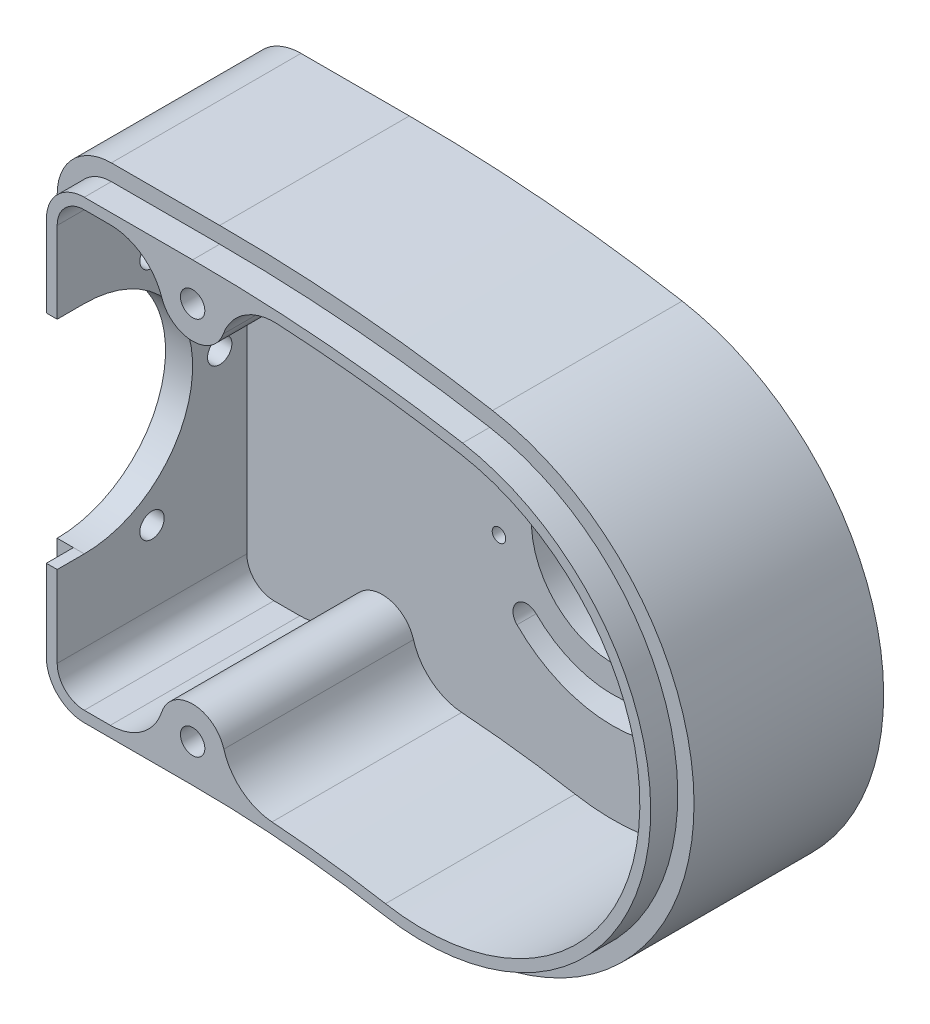
from build123d import *

# Parameters (mm, degrees)
EXTRUDE_1_DEPTH              = 35
CUT_EXTRUDE_1_DEPTH          = 30
SKETCH_3_R                   = 20
SKETCH_3_R_2                 = 2.25
CUT_EXTRUDE_2_DEPTH          = 10
SKETCH_4_R                   = 15
CUT_EXTRUDE_3_DEPTH          = 1
CUT_EXTRUDE_3_DEPTH_BACK     = 36
EXTRUDE_2_DEPTH              = 5
CUT_EXTRUDE_6_REACH          = 42
SKETCH_12_R                  = 6
EXTRUDE_3_DEPTH              = 35
FILLET_1_R                   = 10
HOLE_WIZARD_M2_1_D           = 1.6
HOLE_WIZARD_M2_1_DEPTH       = 5
HOLE_WIZARD_M3_1_D           = 2.5
HOLE_WIZARD_M3_1_DEPTH       = 5
HOLE_WIZARD_M4_6_D           = 4.5
HOLE_WIZARD_M4_6_DEPTH       = 40
HOLE_WIZARD_M4_6_CBORE_D     = 9
HOLE_WIZARD_M4_6_CBORE_DEPTH = 33.1
HOLE_WIZARD_M4_6_TIP         = 1.351936393


with BuildPart() as part:
    # 스케치1 → 보스-돌출1 (new body)
    with BuildSketch(Plane.XY):
        with BuildLine():
            Line((10, 45.518523903), (0, 45.518523903))
            Line((0, 45.518523903), (-10, 45.518523903))
            ThreePointArc((-10, 45.518523903), (-17.071067812, 42.589591715), (-20, 35.518523903))
            Line((-20, 35.518523903), (-20, -34.481476097))
            ThreePointArc((-20, -34.481476097), (-17.071067812, -41.552543909), (-10, -44.481476097))
            Line((-10, -44.481476097), (0, -44.481476097))
            Line((0, -44.481476097), (10, -44.481476097))
            ThreePointArc((10, -44.481476097), (27.43114855, -45.242536479), (44.729635533, -47.519925495))
            ThreePointArc((44.729635533, -47.519925495), (96.860152414, -11.017744604), (60.357971523, 41.112772276))
            ThreePointArc((60.357971523, 41.112772276), (35.275165397, 44.414986349), (10, 45.518523903))
        make_face()
    extrude(amount=EXTRUDE_1_DEPTH)

    # 스케치2 → 컷-돌출1 (cut)
    with BuildSketch(Plane.XY.offset(35)):
        with BuildLine():
            Line((10, 40.518523903), (-10, 40.518523903))
            ThreePointArc((-10, 40.518523903), (-13.535533906, 39.054057809), (-15, 35.518523903))
            Line((-15, 35.518523903), (-15, -34.481476097))
            ThreePointArc((-15, -34.481476097), (-13.535533906, -38.017010003), (-10, -39.481476097))
            Line((-10, -39.481476097), (10, -39.481476097))
            ThreePointArc((10, -39.481476097), (27.866927263, -40.261562989), (45.597876422, -42.59588673))
            ThreePointArc((45.597876422, -42.59588673), (91.936113649, -10.149503716), (59.489730635, 36.188733511))
            ThreePointArc((59.489730635, 36.188733511), (34.839386683, 39.434012859), (10, 40.518523903))
        make_face()
    extrude(amount=-CUT_EXTRUDE_1_DEPTH, mode=Mode.SUBTRACT)

    # 스케치3 → 컷-돌출2 (cut)
    with BuildSketch(Plane.ZY.offset(20)):
        with Locations((35, 0.518523903)):
            Circle(SKETCH_3_R)
        with Locations((22.5, 22.169158997)):
            Circle(SKETCH_3_R_2)
        with Locations((10, 0.518523903)):
            Circle(SKETCH_3_R_2)
        with Locations((22.5, -21.132111192)):
            Circle(SKETCH_3_R_2)
    extrude(amount=-CUT_EXTRUDE_2_DEPTH, mode=Mode.SUBTRACT)

    # 스케치4 → 컷-돌출3 (cut, two sides)
    with BuildSketch(Plane(origin=(0, 0, 0), x_dir=(-1, 0, 0), z_dir=(0, 0, -1))) as cut_extrude_3_sk:
        with Locations((-52.543803528, -3.203576609)):
            Circle(SKETCH_4_R)
    extrude(amount=CUT_EXTRUDE_3_DEPTH, mode=Mode.SUBTRACT)
    extrude(cut_extrude_3_sk.sketch, amount=-CUT_EXTRUDE_3_DEPTH_BACK, mode=Mode.SUBTRACT)

    # 스케치8 → 보스-돌출2 (add)
    with BuildSketch(Plane.XY.offset(35)):
        with BuildLine():
            Line((-15, -19.481476097), (-15, -34.481476097))
            ThreePointArc((-15, -34.481476097), (-13.535533906, -38.017010003), (-10, -39.481476097))
            Line((-10, -39.481476097), (10, -39.481476097))
            ThreePointArc((10, -39.481476097), (27.866927263, -40.261562989), (45.597876422, -42.59588673))
            ThreePointArc((45.597876422, -42.59588673), (91.936113649, -10.149503716), (59.489730635, 36.188733511))
            ThreePointArc((59.489730635, 36.188733511), (34.839386683, 39.434012859), (10, 40.518523903))
            Line((10, 40.518523903), (-10, 40.518523903))
            ThreePointArc((-10, 40.518523903), (-13.535533906, 39.054057809), (-15, 35.518523903))
            Line((-15, 35.518523903), (-15, 20.518523903))
            Line((-15, 20.518523903), (-17, 20.518523903))
            Line((-17, 20.518523903), (-17, 35.518523903))
            ThreePointArc((-17, 35.518523903), (-14.949747468, 40.468271371), (-10, 42.518523903))
            Line((-10, 42.518523903), (10, 42.518523903))
            ThreePointArc((10, 42.518523903), (35.013698169, 41.426402255), (59.83702699, 38.158349017))
            ThreePointArc((59.83702699, 38.158349017), (93.905729155, -10.496800071), (45.250580066, -44.565502236))
            ThreePointArc((45.250580066, -44.565502236), (27.692615778, -42.253952385), (10, -41.481476097))
            Line((10, -41.481476097), (-10, -41.481476097))
            ThreePointArc((-10, -41.481476097), (-14.949747468, -39.431223566), (-17, -34.481476097))
            Line((-17, -34.481476097), (-17, -19.481476097))
            Line((-17, -19.481476097), (-15, -19.481476097))
        make_face()
    extrude(amount=EXTRUDE_2_DEPTH)

    # 스케치9 → 컷-돌출6 (cut, up to next)
    with BuildSketch(Plane(origin=(0, 0, 0), x_dir=(-1, 0, 0), z_dir=(0, 0, -1)), mode=Mode.PRIVATE) as cut_extrude_6_sk1:
        with BuildLine():
            ThreePointArc((-38.401667905, 10.938559014), (-34.866133999, 10.938559014), (-34.866133999, 14.47409292))
            ThreePointArc((-34.866133999, 14.47409292), (-77.543803528, -3.203576609), (-34.866133999, -20.881246139))
            ThreePointArc((-34.866133999, -20.881246139), (-34.866133999, -17.345712233), (-38.401667905, -17.345712233))
            ThreePointArc((-38.401667905, -17.345712233), (-72.543803528, -3.203576609), (-38.401667905, 10.938559014))
        make_face()
    cut_extrude_6_tool1 = extrude(cut_extrude_6_sk1.sketch, amount=-CUT_EXTRUDE_6_REACH, mode=Mode.PRIVATE) & part.part
    add(cut_extrude_6_tool1.solids().sort_by_distance((35.334344, -17.813923, 0))[0], mode=Mode.SUBTRACT)

    # 스케치12 → 보스-돌출3 (add)
    with BuildSketch(Plane.XY.offset(5)):
        with Locations((10, 35.518523903)):
            Circle(SKETCH_12_R)
        with Locations((10, -34.481476097)):
            Circle(SKETCH_12_R)
    extrude(amount=EXTRUDE_3_DEPTH)

    # 필렛1
    fillet_1_edges = [part.edges().sort_by_distance(p)[0] for p in [
        (13.346048824, 40.498881046, 22.5),
        (6.68337521, 40.518523903, 22.5),
        (13.276798635, -39.507666574, 22.5),
        (6.68337521, -39.481476097, 22.5),
    ]]
    fillet(fillet_1_edges, radius=FILLET_1_R)

    # M2 나사 구멍1
    with Locations(Plane.XY.offset(5)):
        with Locations((70.043803528, -3.203576609)):
            Hole(HOLE_WIZARD_M2_1_D / 2, depth=HOLE_WIZARD_M2_1_DEPTH)

    # M3 나사 구멍1
    with Locations(Plane.XY.offset(5)):
        with Locations((31.543803528, 1.796423391), (31.543803528, -8.203576609)):
            Hole(HOLE_WIZARD_M3_1_D / 2, depth=HOLE_WIZARD_M3_1_DEPTH)

    # M4 남비 머리 나사용 카운터보어6
    with Locations(Plane(origin=(0, 0, 0), x_dir=(-1, 0, 0), z_dir=(0, 0, -1))):
        with Locations((-10, 35.518523903), (-10, -34.481476097)):
            CounterBoreHole(HOLE_WIZARD_M4_6_D / 2, HOLE_WIZARD_M4_6_CBORE_D / 2, HOLE_WIZARD_M4_6_CBORE_DEPTH, depth=HOLE_WIZARD_M4_6_DEPTH)
            with Locations((0, 0, -(HOLE_WIZARD_M4_6_DEPTH + HOLE_WIZARD_M4_6_TIP / 2))):  # 118° drill point
                Cone(0, HOLE_WIZARD_M4_6_D / 2, HOLE_WIZARD_M4_6_TIP, mode=Mode.SUBTRACT)


solid = part.part
